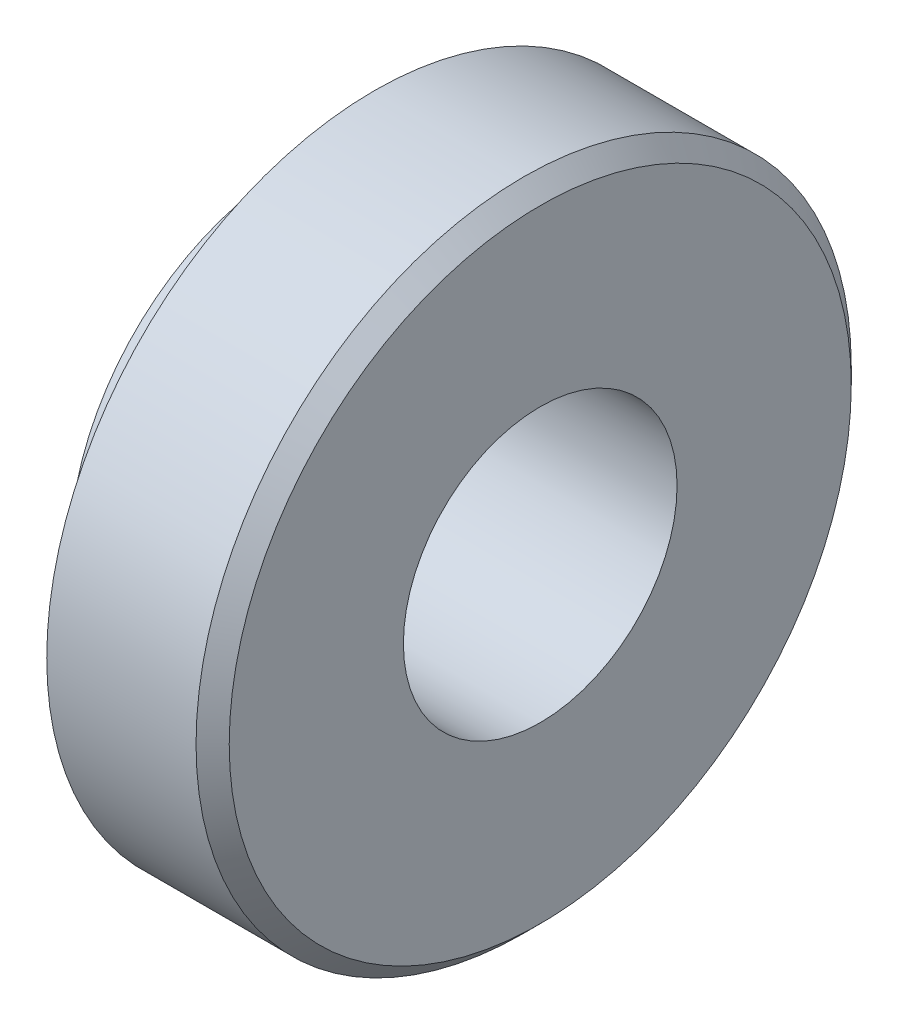
from build123d import *

# Parameters (mm, degrees)
TROU_TARAUD_M4X0_71_D = 3.3
CHANFREIN1_SIZE       = 0.2


with BuildPart() as part:
    # Esquisse1 → Révolution1 (revolve)
    with BuildSketch(Plane.XY, mode=Mode.PRIVATE) as r_volution1_sk:
        Polygon((0, 0), (-2.98, 0), (-2.98, 2.69), (-2, 2.69), (-2, 3.95), (0, 3.95), align=None)
    revolve(r_volution1_sk.sketch.rotate(Axis((0, 0, 0), (1, 0, 0)), 90), axis=Axis((0, 0, 0), (1, 0, 0)))  # turned: the seam where the file's is

    # Trou taraudé M4x0.71 (through all)
    with Locations(Plane(origin=(-2.98, 0, 0), x_dir=(0, 0, -1), z_dir=(-1, 0, 0))):
        with Locations((0, 0)):
            Hole(TROU_TARAUD_M4X0_71_D / 2)

    # Chanfrein1
    chanfrein1_edges = [part.edges().sort_by_distance(p)[0] for p in [
        (0, 0, -3.95),
    ]]
    chamfer(chanfrein1_edges, length=CHANFREIN1_SIZE)


solid = part.part
